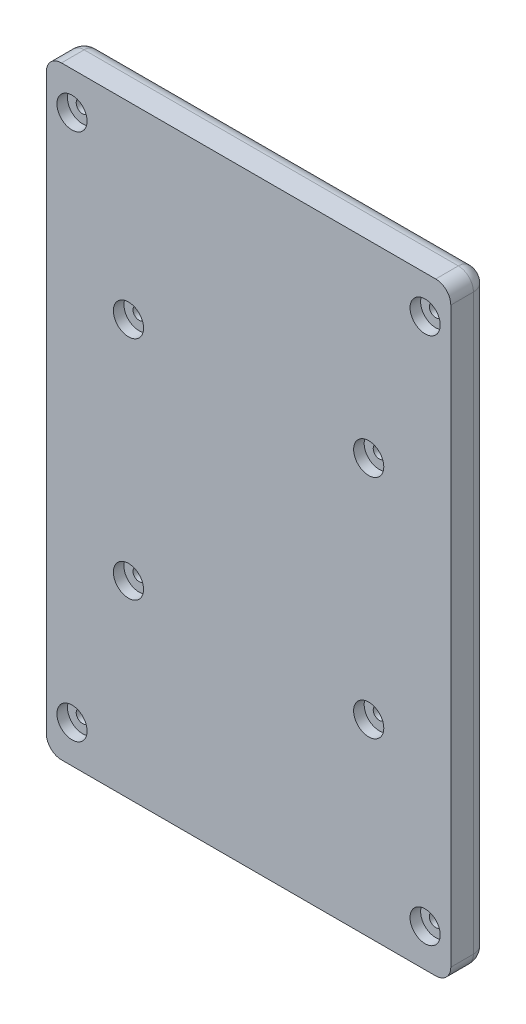
from build123d import *

# Parameters (mm, degrees)
CROQUIS1_W                         = 268
CROQUIS1_H                         = 400
CROQUIS1_R                         = 4
SALIENTE_EXTRUIR1_DEPTH            = 25
CROQUIS2_R                         = 10
CORTAR_EXTRUIR1_DEPTH              = 7
REDONDEO1_R                        = 10
REDONDEO2_R                        = 10
CROQUIS3_R                         = 10
CORTAR_EXTRUIR2_DEPTH              = 7
TALADRO_DE_MARGEN_PARA_5_161_D     = 8.4328
TALADRO_DE_MARGEN_PARA_5_161_DEPTH = 18


with BuildPart() as part:
    # Croquis1 → Saliente-Extruir1 (new body)
    with BuildSketch(Plane.XY):
        with Locations((134, 200)):
            Rectangle(CROQUIS1_W, CROQUIS1_H)
        with Locations((54.405, 275)):
            Circle(CROQUIS1_R, mode=Mode.SUBTRACT)
        with Locations((213.605, 275)):
            Circle(CROQUIS1_R, mode=Mode.SUBTRACT)
        with Locations((213.605, 125)):
            Circle(CROQUIS1_R, mode=Mode.SUBTRACT)
        with Locations((54.405, 125)):
            Circle(CROQUIS1_R, mode=Mode.SUBTRACT)
    extrude(amount=SALIENTE_EXTRUIR1_DEPTH)

    # Croquis2 → Cortar-Extruir1 (cut)
    with BuildSketch(Plane.XY.offset(25)):
        with Locations((54.405, 275)):
            Circle(CROQUIS2_R)
        with Locations((213.605, 275)):
            Circle(CROQUIS2_R)
        with Locations((213.605, 125)):
            Circle(CROQUIS2_R)
        with Locations((54.405, 125)):
            Circle(CROQUIS2_R)
    extrude(amount=-CORTAR_EXTRUIR1_DEPTH, mode=Mode.SUBTRACT)

    # Redondeo1
    redondeo1_edges = [part.edges().sort_by_distance(p)[0] for p in [
        (0, 400, 12.5),
        (268, 400, 12.5),
        (268, 0, 12.5),
        (0, 0, 12.5),
    ]]
    fillet(redondeo1_edges, radius=REDONDEO1_R)

    # Redondeo2
    redondeo2_edges = [part.edges().sort_by_distance(p)[0] for p in [
        (268, 200, 0),
        (0, 200, 0),
        (134, 400, 0),
        (134, 0, 0),
        (2.928932188, 397.071067812, 0),
        (265.071067812, 397.071067812, 0),
        (2.928932188, 2.928932188, 0),
        (265.071067812, 2.928932188, 0),
    ]]
    fillet(redondeo2_edges, radius=REDONDEO2_R)

    # Croquis3 → Cortar-Extruir2 (cut)
    with BuildSketch(Plane.XY.offset(25)):
        with Locations((17, 375)):
            Circle(CROQUIS3_R)
        with Locations((251, 375)):
            Circle(CROQUIS3_R)
        with Locations((251, 25)):
            Circle(CROQUIS3_R)
        with Locations((17, 25)):
            Circle(CROQUIS3_R)
    extrude(amount=-CORTAR_EXTRUIR2_DEPTH, mode=Mode.SUBTRACT)

    # Taladro de margen para 5/161
    with Locations(Plane.XY.offset(18)):
        with Locations((17, 25), (251, 25), (251, 375), (17, 375)):
            Hole(TALADRO_DE_MARGEN_PARA_5_161_D / 2, depth=TALADRO_DE_MARGEN_PARA_5_161_DEPTH)


solid = part.part
